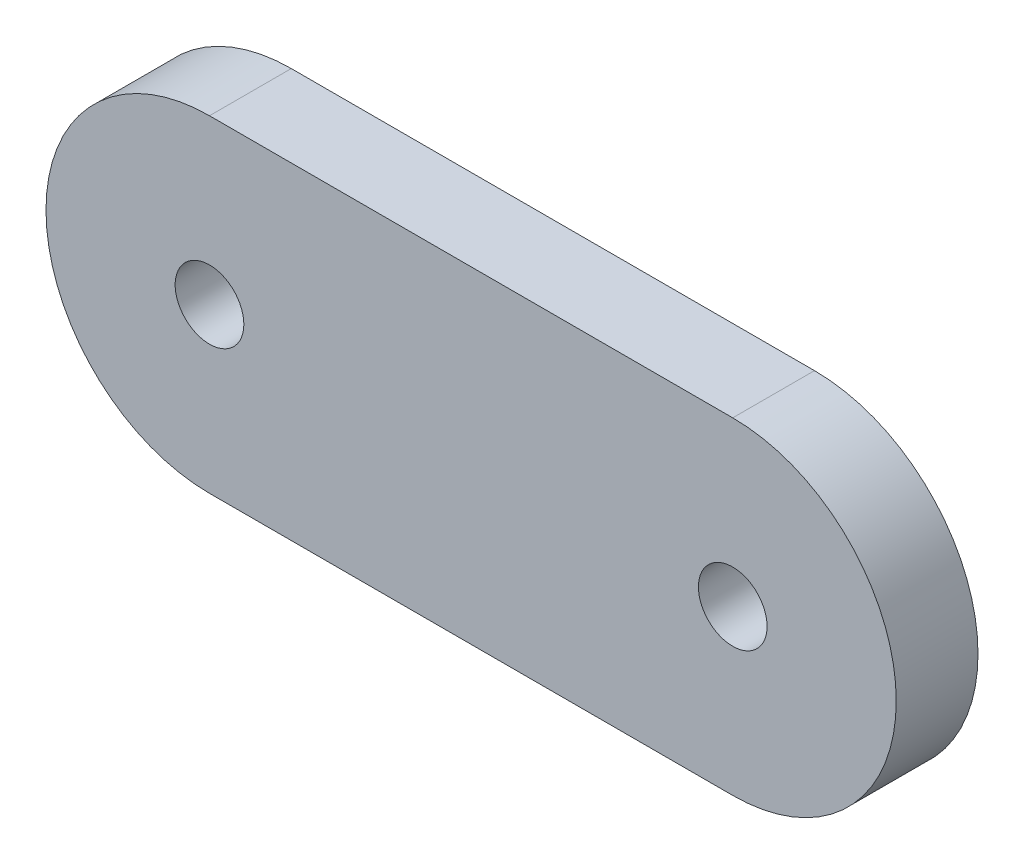
from build123d import *

# Parameters (mm, degrees)
SKETCH1_R           = 2.1
BOSS_EXTRUDE1_DEPTH = 5


with BuildPart() as part:
    # Sketch1 → Boss-Extrude1 (new body)
    with BuildSketch(Plane.XY):
        with BuildLine():
            Line((-43.715181522, 10), (-11.715181522, 10))
            ThreePointArc((-11.715181522, 10), (-1.715181522, 0), (-11.715181522, -10))
            Line((-11.715181522, -10), (-43.715181522, -10))
            ThreePointArc((-43.715181522, -10), (-53.715181522, 0), (-43.715181522, 10))
        make_face()
        with Locations((-43.715181522, 0)):
            Circle(SKETCH1_R, mode=Mode.SUBTRACT)
        with Locations((-11.715181522, 0)):
            Circle(SKETCH1_R, mode=Mode.SUBTRACT)
    extrude(amount=BOSS_EXTRUDE1_DEPTH)


solid = part.part
